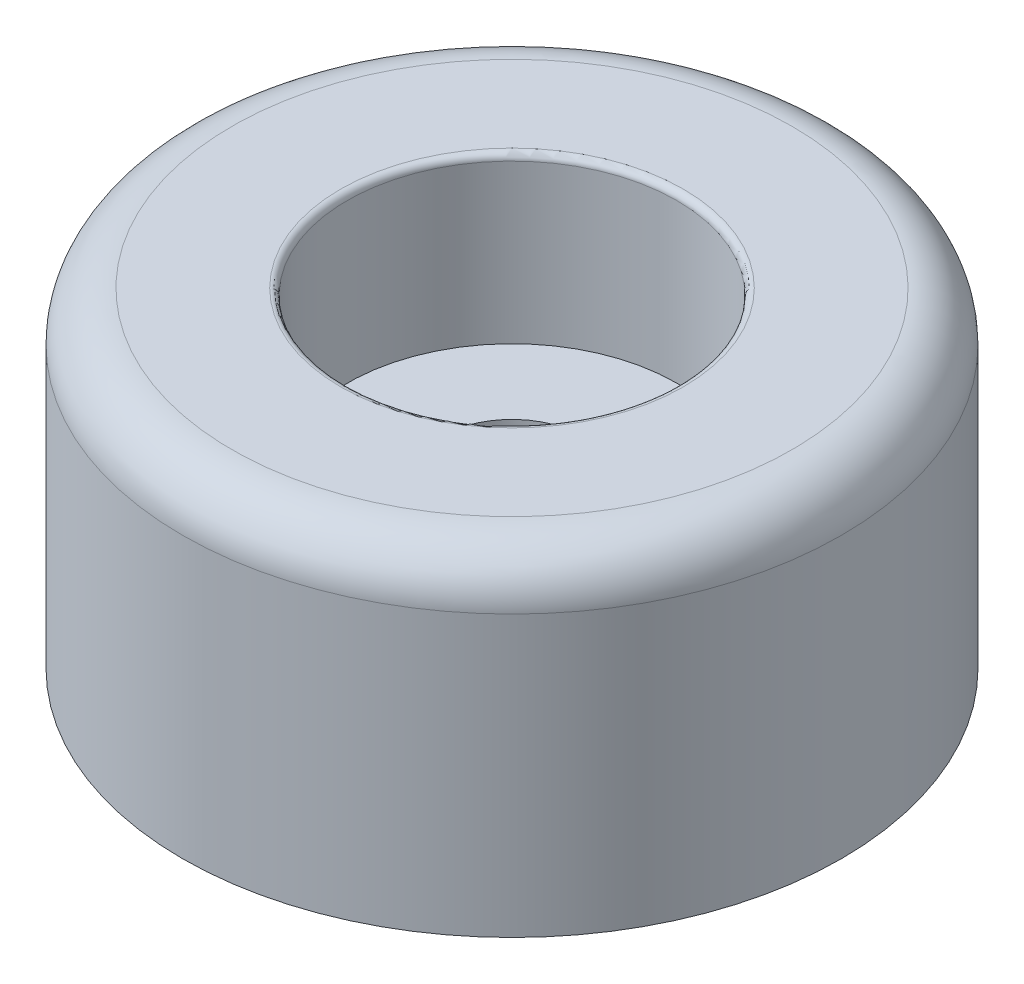
from build123d import *

# Parameters (mm, degrees)
FILLET1_R = 0.254


with BuildPart() as part:
    # Sketch2 → Revolve1 (revolve)
    with BuildSketch(Plane.XY):
        with BuildLine():
            Line((-12.7, 0), (-12.7, 10.795))
            ThreePointArc((-12.7, 10.795), (-12.142038418, 12.142038418), (-10.795, 12.7))
            Line((-10.795, 12.7), (-6.35, 12.7))
            Line((-6.35, 12.7), (-6.35, 6.35))
            Line((-6.35, 6.35), (-2.778125, 6.35))
            Line((-2.778125, 6.35), (-2.778125, 0))
            Line((-2.778125, 0), (-12.7, 0))
        make_face()
    revolve(axis=Axis((0, 0, 0), (0, 1, 0)))

    # Fillet1
    fillet1_edges = [part.edges().sort_by_distance(p)[0] for p in [
        (6.35, 12.7, 0),
    ]]
    fillet(fillet1_edges, radius=FILLET1_R)


solid = part.part
